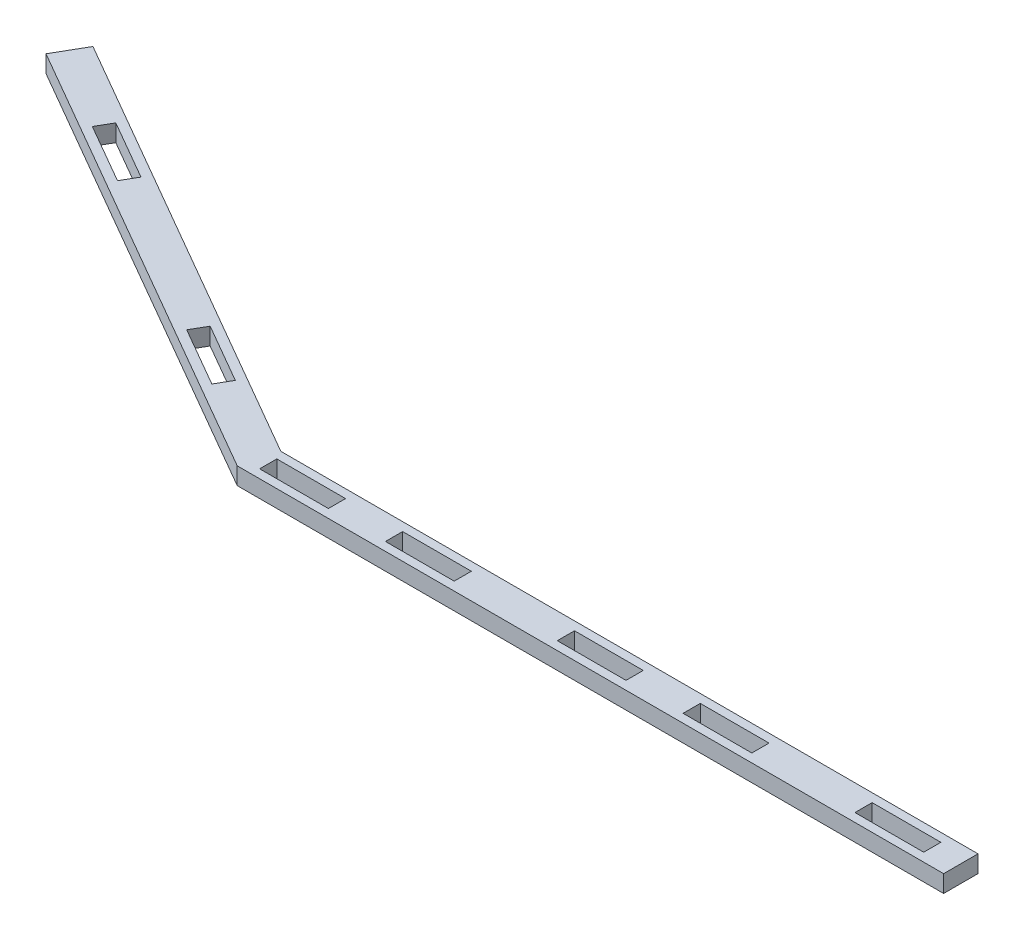
from build123d import *

# Parameters (mm, degrees)
BOSS_EXTRUDE2_DEPTH = 6.35


with BuildPart() as part:
    # Sketch4 → Boss-Extrude2 (new body)
    with BuildSketch(Plane(origin=(0, 0, 0), x_dir=(1, 0, 0), z_dir=(0, 1, 0))):
        Polygon((-428.205616447, 90.176116322), (-421.855616447, 101.17463895), (-257.614523887, 6.349999946), (-1e-09, 6.35), (1e-09, -6.35), (-261.017478725, -6.35), align=None)
        Polygon((-396.37217922, 75.463246979), (-374.375133964, 62.763246979), (-371.200133964, 68.262508293), (-393.19717922, 80.962508293), align=None, mode=Mode.SUBTRACT)
        Polygon((-313.88325951, 27.838246978), (-291.886214254, 15.138246977), (-288.711214254, 20.637508291), (-310.70825951, 33.337508292), align=None, mode=Mode.SUBTRACT)
        Polygon((-255.913065771, 3.174999946), (-255.913065769, -3.175000054), (-230.513065769, -3.175000048), (-230.513065771, 3.174999952), align=None, mode=Mode.SUBTRACT)
        Polygon((-209.427839463, 3.174999956), (-209.427839461, -3.175000044), (-184.027839461, -3.175000038), (-184.027839463, 3.174999962), align=None, mode=Mode.SUBTRACT)
        Polygon((-120.527839461, -3.175000025), (-120.527839463, 3.174999975), (-145.927839463, 3.174999969), (-145.927839461, -3.175000031), align=None, mode=Mode.SUBTRACT)
        Polygon((-99.442613155, 3.174999979), (-99.442613153, -3.175000021), (-74.042613153, -3.175000015), (-74.042613155, 3.174999985), align=None, mode=Mode.SUBTRACT)
        Polygon((-10.542613153, -3.175000002), (-10.542613155, 3.174999998), (-35.942613155, 3.174999993), (-35.942613153, -3.175000007), align=None, mode=Mode.SUBTRACT)
    extrude(amount=BOSS_EXTRUDE2_DEPTH)


solid = part.part
